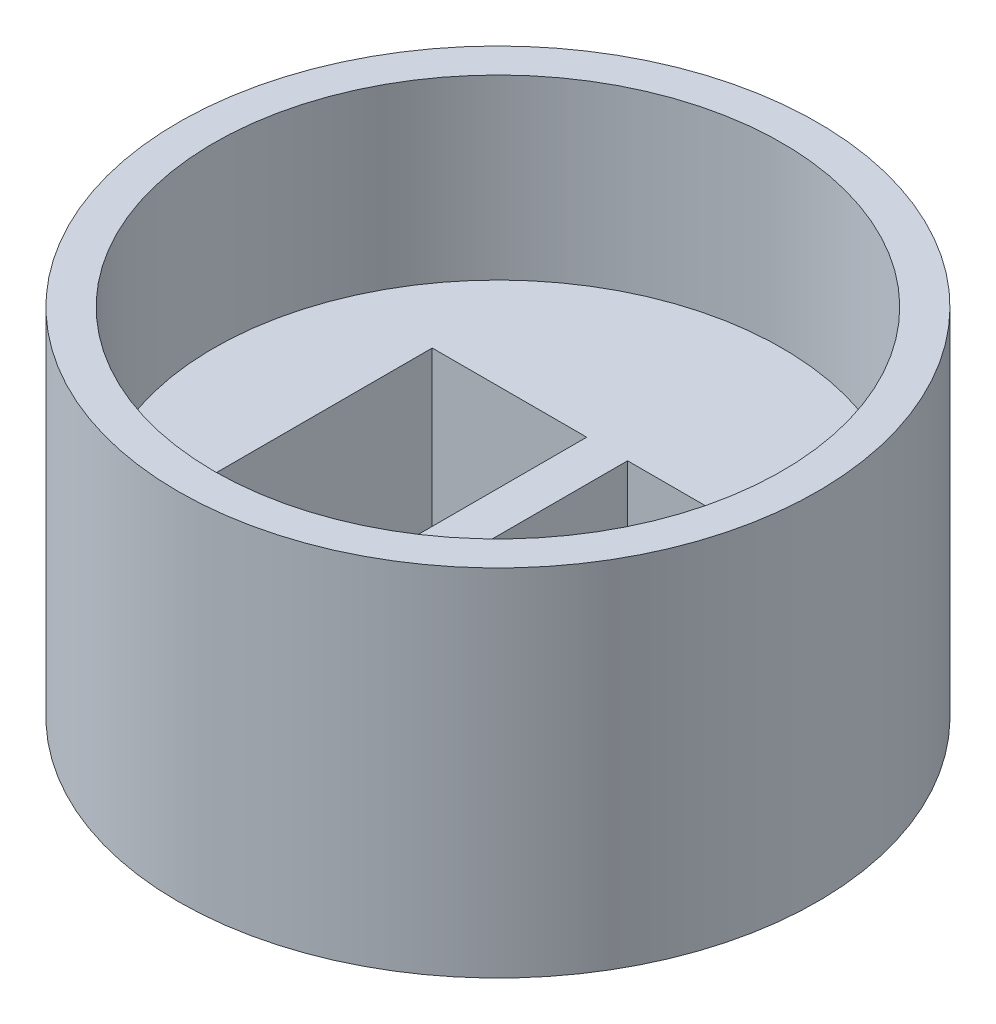
from build123d import *

# Parameters (mm, degrees)
SKETCH2_R           = 9
BOSS_EXTRUDE2_DEPTH = 10
SKETCH3_R           = 8
CUT_EXTRUDE1_DEPTH  = 5
SKETCH4_W           = 4.35
SKETCH4_H           = 6.15
CUT_EXTRUDE2_DEPTH  = 6


with BuildPart() as part:
    # Sketch2 → Boss-Extrude2 (new body)
    with BuildSketch(Plane(origin=(0, 0, 0), x_dir=(1, 0, 0), z_dir=(0, 1, 0))):
        Circle(SKETCH2_R)
    extrude(amount=BOSS_EXTRUDE2_DEPTH)

    # Sketch3 → Cut-Extrude1 (cut)
    with BuildSketch(Plane(origin=(0, 10, 0), x_dir=(1, 0, 0), z_dir=(0, 1, 0))):
        Circle(SKETCH3_R)
    extrude(amount=-CUT_EXTRUDE1_DEPTH, mode=Mode.SUBTRACT)

    # Sketch4 → Cut-Extrude2 (cut, through all)
    with BuildSketch(Plane(origin=(0, 5, 0), x_dir=(1, 0, 0), z_dir=(0, 1, 0))):
        with Locations((2.75, 0)):
            Rectangle(SKETCH4_W, SKETCH4_H)
        with Locations((-2.75, 0)):
            Rectangle(SKETCH4_W, SKETCH4_H)
    extrude(amount=-CUT_EXTRUDE2_DEPTH, mode=Mode.SUBTRACT)


solid = part.part
